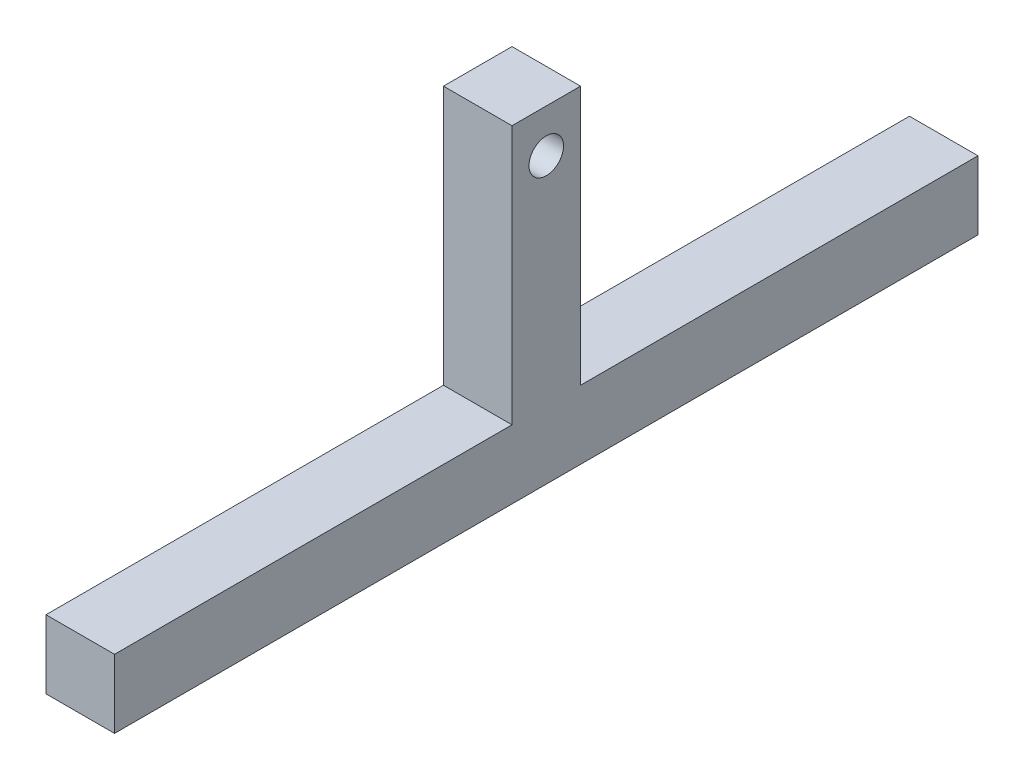
from build123d import *

# Parameters (mm, degrees)
SKETCH1_W           = 200
SKETCH1_H           = 15.875
SKETCH1_W_2         = 15.875
SKETCH1_H_2         = 60
BOSS_EXTRUDE1_DEPTH = 15.875
SKETCH2_R           = 4
CUT_EXTRUDE1_DEPTH  = 16.875


with BuildPart() as part:
    # Sketch1 → Boss-Extrude1 (new body)
    with BuildSketch(Plane(origin=(0, 0, 0), x_dir=(0, 0, -1), z_dir=(1, 0, 0))):
        Rectangle(SKETCH1_W, SKETCH1_H)
        with Locations((0, 37.9375)):
            Rectangle(SKETCH1_W_2, SKETCH1_H_2)
    extrude(amount=BOSS_EXTRUDE1_DEPTH)

    # Sketch2 → Cut-Extrude1 (cut, through all)
    with BuildSketch(Plane(origin=(15.875, 0, 0), x_dir=(0, 0, -1), z_dir=(1, 0, 0))):
        with Locations((0, 57.9375)):
            Circle(SKETCH2_R)
    extrude(amount=-CUT_EXTRUDE1_DEPTH, mode=Mode.SUBTRACT)


solid = part.part
